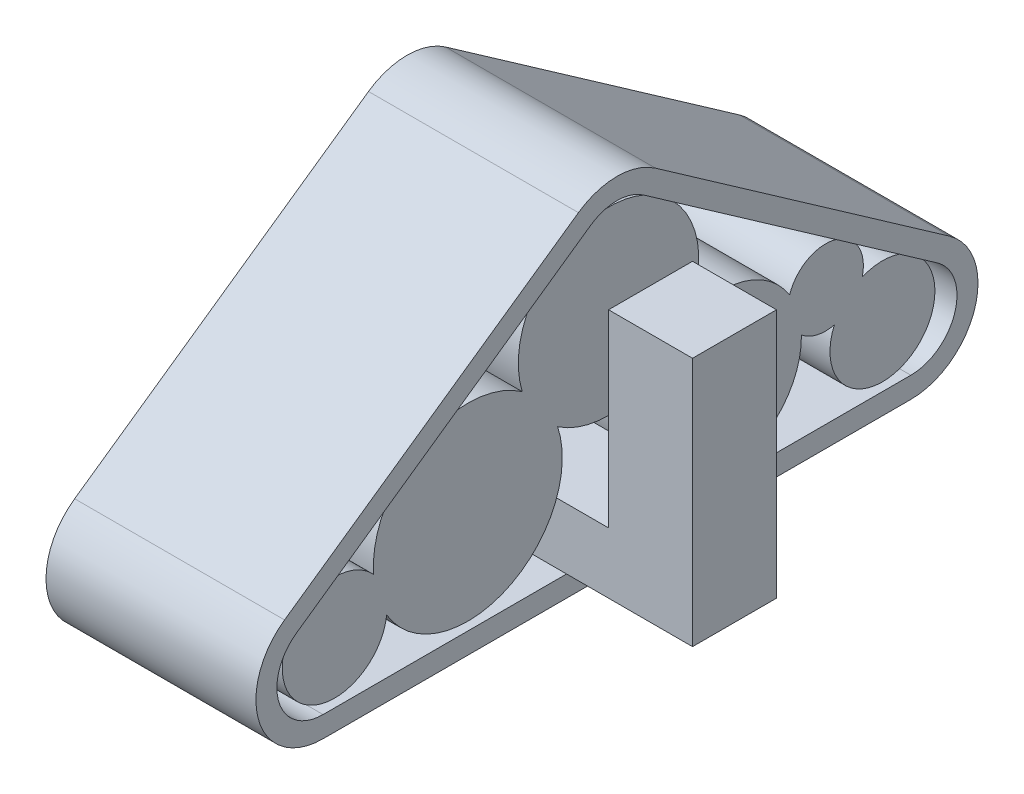
from build123d import *

# Parameters (mm, degrees)
TREADS_DEPTH                   = 2.5
CIRCLES_DEPTH                  = 1.15
CIRCLES_DEPTH_BACK             = 1.15
BOTTOM_OF_CONNECTOR_DEPTH      = 2.75
BOTTOM_OF_CONNECTOR_DEPTH_BACK = 1.25
SKETCH3_5_W                    = 1
SKETCH3_5_H                    = 0.725
SKETCH4_W                      = 1
SKETCH4_H                      = 1
TOP_OF_CONNECTOR_DEPTH         = 2.25


with BuildPart() as part:
    # Sketch1 → Treads (new body)
    with BuildSketch(Plane(origin=(0, 0, 0), x_dir=(0, 0, -1), z_dir=(1, 0, 0))):
        with BuildLine():
            Line((-3, 0), (3, 0))
            Line((3, 0), (3.5, 0))
            ThreePointArc((3.5, 0), (4.262973561, 0.55943536), (3.958861149, 1.455321635))
            Line((3.958861149, 1.455321635), (0.458861149, 3.906048019))
            ThreePointArc((0.458861149, 3.906048019), (0, 4.050726384), (-0.458861149, 3.906048019))
            Line((-0.458861149, 3.906048019), (-3.958861149, 1.455321635))
            ThreePointArc((-3.958861149, 1.455321635), (-4.262973561, 0.55943536), (-3.5, 0))
            Line((-3.5, 0), (-3, 0))
        make_face()
        with BuildLine():
            ThreePointArc((0, 3.800726384), (0.16538819, 3.775270707), (0.31546704, 3.701260008))
            Line((0.31546704, 3.701260008), (3.81546704, 1.250533624))
            ThreePointArc((3.81546704, 1.250533624), (4.024544323, 0.63461181), (3.5, 0.25))
            Line((3.5, 0.25), (-3.5, 0.25))
            ThreePointArc((-3.5, 0.25), (-4.024544323, 0.63461181), (-3.81546704, 1.250533624))
            Line((-3.81546704, 1.250533624), (-0.31546704, 3.701260008))
            ThreePointArc((-0.31546704, 3.701260008), (-0.16538819, 3.775270707), (0, 3.800726384))
        make_face(mode=Mode.SUBTRACT)
    extrude(amount=TREADS_DEPTH)

    # Sketch3_5 → Bottom of Connector (add, two sides: drawn at the far end of the back side and taken through both)
    with BuildSketch(Plane(origin=(1.25, 0, 0), x_dir=(0, 0, -1), z_dir=(1, 0, 0)).offset(-BOTTOM_OF_CONNECTOR_DEPTH_BACK)):
        with Locations((-0.1, 0.6125)):
            Rectangle(SKETCH3_5_W, SKETCH3_5_H)
    extrude(amount=BOTTOM_OF_CONNECTOR_DEPTH + BOTTOM_OF_CONNECTOR_DEPTH_BACK)

    # Sketch4 → Top of Connector (add)
    with BuildSketch(Plane(origin=(0, 0.975, 0), x_dir=(1, 0, 0), z_dir=(0, 1, 0))):
        with Locations((3.5, -0.1)):
            Rectangle(SKETCH4_W, SKETCH4_H)
    extrude(amount=TOP_OF_CONNECTOR_DEPTH)


with BuildPart() as body_2:
    # Sketch3 → Circles (new, two sides: drawn at the far end of the back side and taken through both)
    with BuildSketch(Plane(origin=(1.25, 0, 0), x_dir=(0, 0, -1), z_dir=(1, 0, 0)).offset(-CIRCLES_DEPTH_BACK)):
        with BuildLine():
            ThreePointArc((-2.641926718, 0.797718657), (-1.211224345, 0.350647058), (-0.606199298, 1.722043057))
            ThreePointArc((-0.606199298, 1.722043057), (-0.049783758, 1.535973098), (0.521460622, 1.669764503))
            ThreePointArc((0.521460622, 1.669764503), (1.112446431, 0.279457962), (2.297033365, 1.216992122))
            ThreePointArc((2.297033365, 1.216992122), (2.482253195, 1.124579804), (2.68924678, 1.124858699))
            ThreePointArc((2.68924678, 1.124858699), (3.700598319, 0.429611546), (3.021273042, 1.451725878))
            ThreePointArc((3.021273042, 1.451725878), (2.708453629, 1.995435529), (2.15606319, 1.698213434))
            ThreePointArc((2.15606319, 1.698213434), (1.60374964, 2.114699273), (0.915404217, 2.046206275))
            ThreePointArc((0.915404217, 2.046206275), (0.136054833, 3.676175239), (-1.027595727, 2.294110965))
            ThreePointArc((-1.027595727, 2.294110965), (-2.229550715, 2.354579066), (-2.798416042, 1.294039382))
            ThreePointArc((-2.798416042, 1.294039382), (-3.858203484, 0.687058875), (-2.641926718, 0.797718657))
        make_face()
    extrude(amount=CIRCLES_DEPTH + CIRCLES_DEPTH_BACK)


solid = Compound([part.part, body_2.part])
